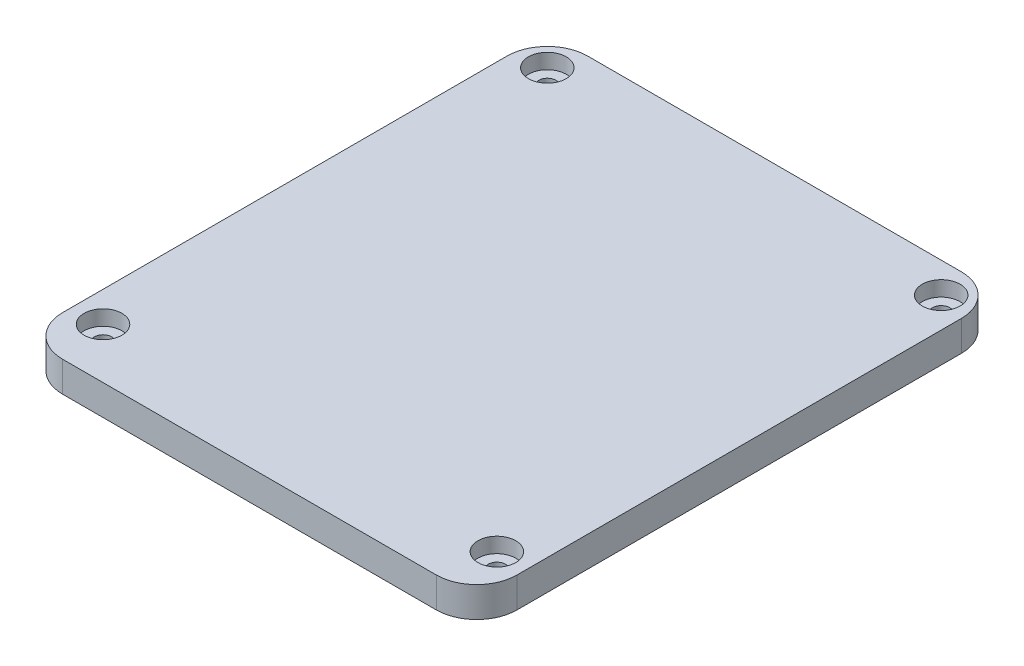
from build123d import *

# Parameters (mm, degrees)
SKETCH1_W           = 90
SKETCH1_H           = 100
BOSS_EXTRUDE1_DEPTH = 3
SKETCH2_R           = 1.7
CUT_EXTRUDE1_DEPTH  = 4
SKETCH4_W           = 81.2
SKETCH4_H           = 93.2
SKETCH4_W_2         = 75.2
SKETCH4_H_2         = 87.2
BOSS_EXTRUDE2_DEPTH = 2
CUT_EXTRUDE5_START  = -3
SKETCH6_R           = 6
CUT_EXTRUDE5_DEPTH  = 3
SKETCH7_W           = 90
SKETCH7_H           = 3
BOSS_EXTRUDE3_DEPTH = 4
SKETCH8_R           = 3.75
BOSS_EXTRUDE4_DEPTH = 3
FILLET1_R           = 8


with BuildPart() as part:
    # Sketch1 → Boss-Extrude1 (new body)
    with BuildSketch(Plane(origin=(0, 0, 0), x_dir=(1, 0, 0), z_dir=(0, 1, 0))):
        Rectangle(SKETCH1_W, SKETCH1_H)
    extrude(amount=BOSS_EXTRUDE1_DEPTH)

    # Sketch2 → Cut-Extrude1 (cut, through all)
    with BuildSketch(Plane(origin=(0, 3, 0), x_dir=(1, 0, 0), z_dir=(0, 1, 0))):
        with Locations((-39, 44)):
            Circle(SKETCH2_R)
        with Locations((39, 44)):
            Circle(SKETCH2_R)
        with Locations((39, -44)):
            Circle(SKETCH2_R)
        with Locations((-39, -44)):
            Circle(SKETCH2_R)
    extrude(amount=-CUT_EXTRUDE1_DEPTH, mode=Mode.SUBTRACT)

    # Sketch4 → Boss-Extrude2 (add)
    with BuildSketch(Plane.XZ):
        with Locations((1, 0)):
            Rectangle(SKETCH4_W, SKETCH4_H)
        with Locations((1, 0)):
            Rectangle(SKETCH4_W_2, SKETCH4_H_2, mode=Mode.SUBTRACT)
    extrude(amount=BOSS_EXTRUDE2_DEPTH)

    # Sketch6 → Cut-Extrude5 (cut, through all)
    with BuildSketch(Plane(origin=(0, 3, 0), x_dir=(1, 0, 0), z_dir=(0, 1, 0)).offset(CUT_EXTRUDE5_START)):
        with Locations((-39, 44)):
            Circle(SKETCH6_R)
        with Locations((-39, -44)):
            Circle(SKETCH6_R)
        with Locations((39, -44)):
            Circle(SKETCH6_R)
        with Locations((39, 44)):
            Circle(SKETCH6_R)
    extrude(amount=-CUT_EXTRUDE5_DEPTH, mode=Mode.SUBTRACT)

    # Sketch7 → Boss-Extrude3 (add)
    with BuildSketch(Plane.XY.offset(50)):
        with Locations((0, 1.5)):
            Rectangle(SKETCH7_W, SKETCH7_H)
    extrude(amount=BOSS_EXTRUDE3_DEPTH)

    # Sketch8 → Boss-Extrude4 (add)
    with BuildSketch(Plane(origin=(0, 3, 0), x_dir=(1, 0, 0), z_dir=(0, 1, 0))):
        Polygon((-45, -50), (-45, -54), (45, -54), (45, -50), (45, 50), (-45, 50), align=None)
        with Locations((-39, 44)):
            Circle(SKETCH8_R, mode=Mode.SUBTRACT)
        with Locations((39, 44)):
            Circle(SKETCH8_R, mode=Mode.SUBTRACT)
        with Locations((-39, -44)):
            Circle(SKETCH8_R, mode=Mode.SUBTRACT)
        with Locations((39, -44)):
            Circle(SKETCH8_R, mode=Mode.SUBTRACT)
    extrude(amount=BOSS_EXTRUDE4_DEPTH)

    # Fillet1
    fillet1_edges = [part.edges().sort_by_distance(p)[0] for p in [
        (-45, 3, 54),
        (45, 3, 54),
        (-45, 3, -50),
        (45, 3, -50),
    ]]
    fillet(fillet1_edges, radius=FILLET1_R)


solid = part.part
